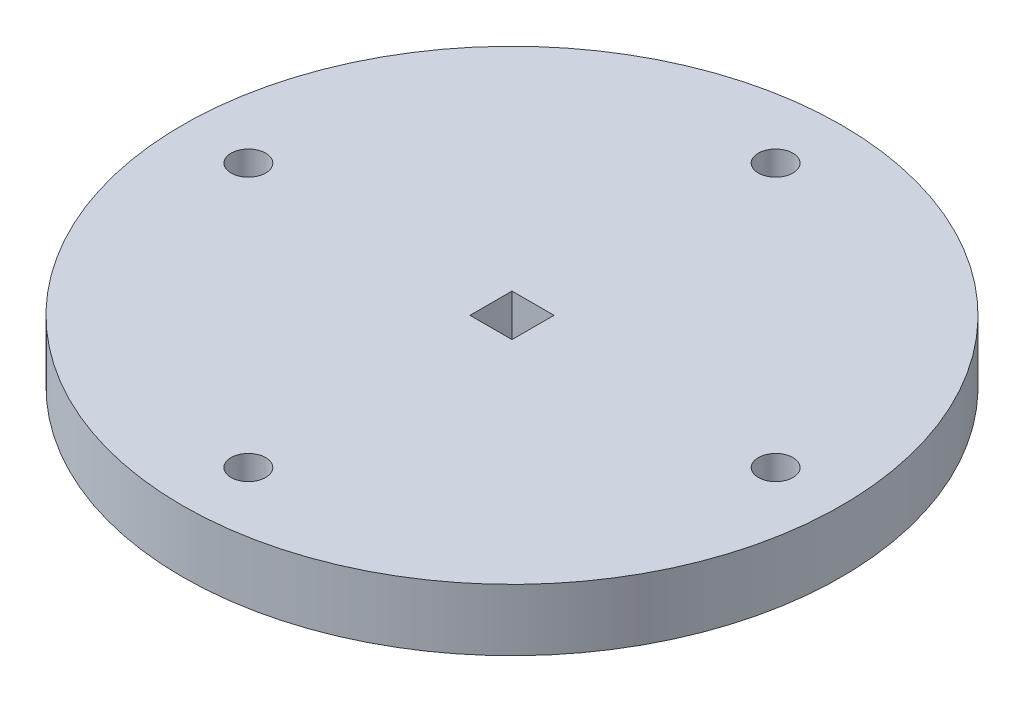
from build123d import *

# Parameters (mm, degrees)
SKETCH2_R           = 50.8
BOSS_EXTRUDE1_DEPTH = 9.525
SKETCH3_R           = 2.667
CUT_EXTRUDE1_DEPTH  = 10.525
SKETCH4_W           = 6.477
SKETCH4_H           = 6.477
CUT_EXTRUDE2_DEPTH  = 10.525


with BuildPart() as part:
    # Sketch2 → Boss-Extrude1 (new body)
    with BuildSketch(Plane(origin=(0, 0, 0), x_dir=(1, 0, 0), z_dir=(0, 1, 0))):
        Circle(SKETCH2_R)
    extrude(amount=BOSS_EXTRUDE1_DEPTH)

    # Sketch3 → Cut-Extrude1 (cut, through all)
    with BuildSketch(Plane(origin=(0, 9.525, 0), x_dir=(1, 0, 0), z_dir=(0, 1, 0))):
        with Locations((0, -40.64)):
            Circle(SKETCH3_R)
        with Locations((-40.64, 0)):
            Circle(SKETCH3_R)
        with Locations((0, 40.64)):
            Circle(SKETCH3_R)
        with Locations((40.64, 0)):
            Circle(SKETCH3_R)
    extrude(amount=-CUT_EXTRUDE1_DEPTH, mode=Mode.SUBTRACT)

    # Sketch4 → Cut-Extrude2 (cut, through all)
    with BuildSketch(Plane(origin=(0, 9.525, 0), x_dir=(1, 0, 0), z_dir=(0, 1, 0))):
        Rectangle(SKETCH4_W, SKETCH4_H)
    extrude(amount=-CUT_EXTRUDE2_DEPTH, mode=Mode.SUBTRACT)


solid = part.part
